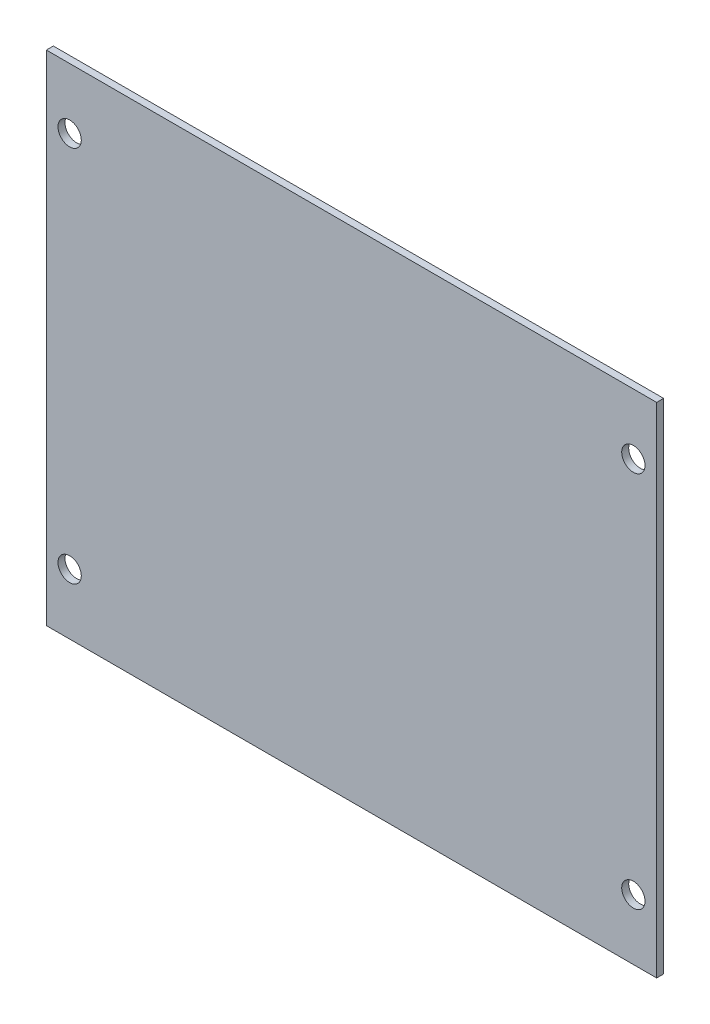
from build123d import *

# Parameters (mm, degrees)
CROQUIS1_W              = 131
CROQUIS1_H              = 107
SALIENTE_EXTRUIR1_DEPTH = 1.5
CORTAR_EXTRUIR1_REACH   = 3.5
CROQUIS2_R              = 2.5


with BuildPart() as part:
    # Croquis1 → Saliente-Extruir1 (new body)
    with BuildSketch(Plane.XY):
        with Locations((10.464475059, -16.940687004)):
            Rectangle(CROQUIS1_W, CROQUIS1_H)
    extrude(amount=SALIENTE_EXTRUIR1_DEPTH)

    # Croquis2 → Cortar-Extruir1 (cut, up to next)
    with BuildSketch(Plane.XY.offset(1.5), mode=Mode.PRIVATE) as cortar_extruir1_sk1:
        with Locations((-50.035524941, 23.559312996)):
            Circle(CROQUIS2_R)
    cortar_extruir1_tool1 = extrude(cortar_extruir1_sk1.sketch, amount=-CORTAR_EXTRUIR1_REACH, mode=Mode.PRIVATE) & part.part
    add(cortar_extruir1_tool1.solids().sort_by_distance((-50.035525, 23.559313, 1.5))[0], mode=Mode.SUBTRACT)
    # Croquis2 → Cortar-Extruir1 (cut, up to next)
    with BuildSketch(Plane.XY.offset(1.5), mode=Mode.PRIVATE) as cortar_extruir1_sk2:
        with Locations((70.964475059, 23.559312996)):
            Circle(CROQUIS2_R)
    cortar_extruir1_tool2 = extrude(cortar_extruir1_sk2.sketch, amount=-CORTAR_EXTRUIR1_REACH, mode=Mode.PRIVATE) & part.part
    add(cortar_extruir1_tool2.solids().sort_by_distance((70.964475, 23.559313, 1.5))[0], mode=Mode.SUBTRACT)
    # Croquis2 → Cortar-Extruir1 (cut, up to next)
    with BuildSketch(Plane.XY.offset(1.5), mode=Mode.PRIVATE) as cortar_extruir1_sk3:
        with Locations((70.964475059, -57.440687004)):
            Circle(CROQUIS2_R)
    cortar_extruir1_tool3 = extrude(cortar_extruir1_sk3.sketch, amount=-CORTAR_EXTRUIR1_REACH, mode=Mode.PRIVATE) & part.part
    add(cortar_extruir1_tool3.solids().sort_by_distance((70.964475, -57.440687, 1.5))[0], mode=Mode.SUBTRACT)
    # Croquis2 → Cortar-Extruir1 (cut, up to next)
    with BuildSketch(Plane.XY.offset(1.5), mode=Mode.PRIVATE) as cortar_extruir1_sk4:
        with Locations((-50.035524941, -57.440687004)):
            Circle(CROQUIS2_R)
    cortar_extruir1_tool4 = extrude(cortar_extruir1_sk4.sketch, amount=-CORTAR_EXTRUIR1_REACH, mode=Mode.PRIVATE) & part.part
    add(cortar_extruir1_tool4.solids().sort_by_distance((-50.035525, -57.440687, 1.5))[0], mode=Mode.SUBTRACT)


solid = part.part
